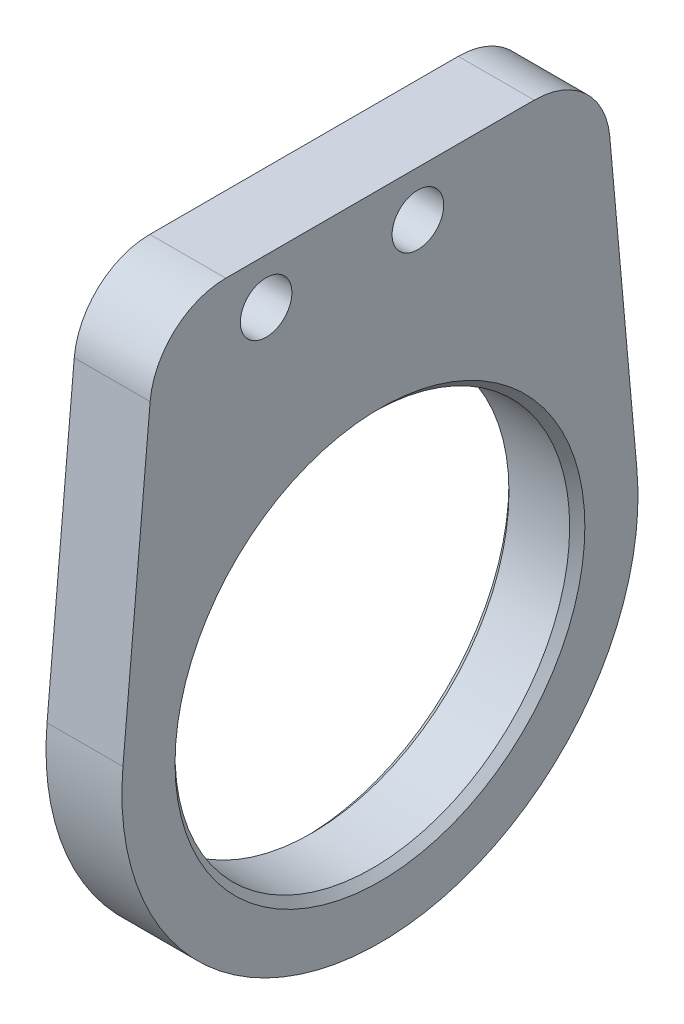
from build123d import *

# Parameters (mm, degrees)
SKETCH_1_R         = 17
SKETCH_1_R_2       = 13
SKETCH_1_W         = 30
SKETCH_1_H         = 3
EXTRUDE_1_DEPTH    = 5
FILLET_1_R         = 5
HOLE_WIZARD_M3_1_D = 3.4
CHAMFER1_SIZE      = 0.5


with BuildPart() as part:
    # 草图1 → 凸台-拉伸1 (new body)
    with BuildSketch(Plane(origin=(0, 0, 0), x_dir=(0, 0, -1), z_dir=(1, 0, 0))):
        Circle(SKETCH_1_R)
        Circle(SKETCH_1_R_2, mode=Mode.SUBTRACT)
        with BuildLine():
            Line((15, 23), (-15, 23))
            Line((-15, 23), (-16.931656145, 1.522832949))
            ThreePointArc((-16.931656145, 1.522832949), (0, 17), (16.931656145, 1.522832949))
            Line((16.931656145, 1.522832949), (15, 23))
        make_face()
        with Locations((0, 24.5)):
            Rectangle(SKETCH_1_W, SKETCH_1_H)
    extrude(amount=EXTRUDE_1_DEPTH)

    # 圆角1
    fillet_1_edges = [part.edges().sort_by_distance(p)[0] for p in [
        (2.5, 26, 15),
        (2.5, 26, -15),
    ]]
    fillet(fillet_1_edges, radius=FILLET_1_R)

    # M3 间隙孔1 (through all)
    with Locations(Plane.ZY):
        with Locations((-2.5, 23), (7.5, 23)):
            Hole(HOLE_WIZARD_M3_1_D / 2)

    # Chamfer1
    chamfer1_edges = [part.edges().sort_by_distance(p)[0] for p in [
        (0, 0, 13),
        (5, 0, 13),
    ]]
    chamfer(chamfer1_edges, length=CHAMFER1_SIZE)


solid = part.part
